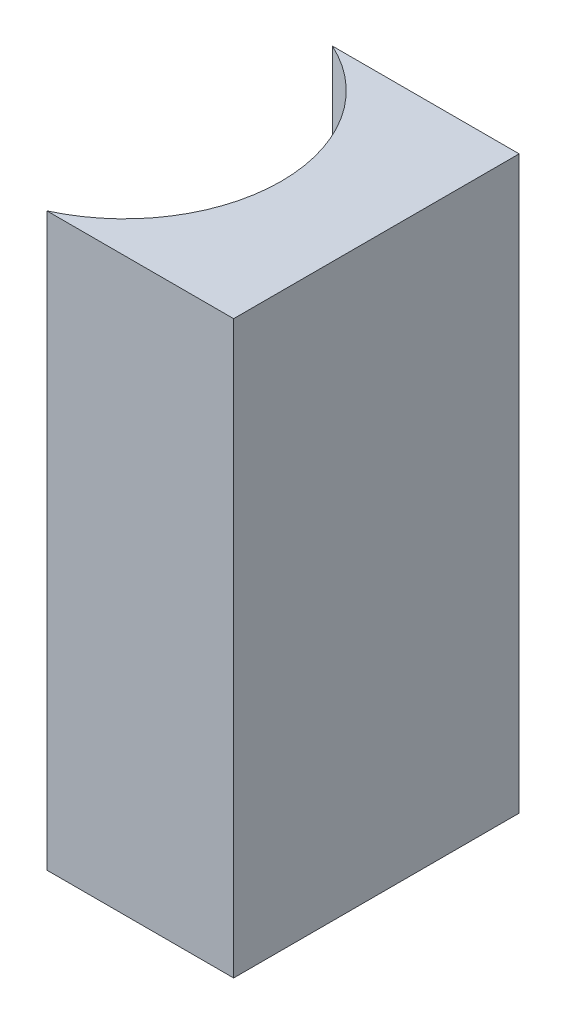
from build123d import *

# Parameters (mm, degrees)
EXTRUDE_1_DEPTH = 12


with BuildPart() as part:
    # 草图1 → 凸台-拉伸1 (new body)
    with BuildSketch(Plane(origin=(0, 0, 0), x_dir=(1, 0, 0), z_dir=(0, 1, 0))):
        with BuildLine():
            Line((0, 0), (0, -6))
            Line((0, -6), (-3.925227292, -6))
            ThreePointArc((-3.925227292, -6), (-2, -3), (-3.925227292, 0))
            Line((-3.925227292, 0), (0, 0))
        make_face()
    extrude(amount=EXTRUDE_1_DEPTH)


solid = part.part
